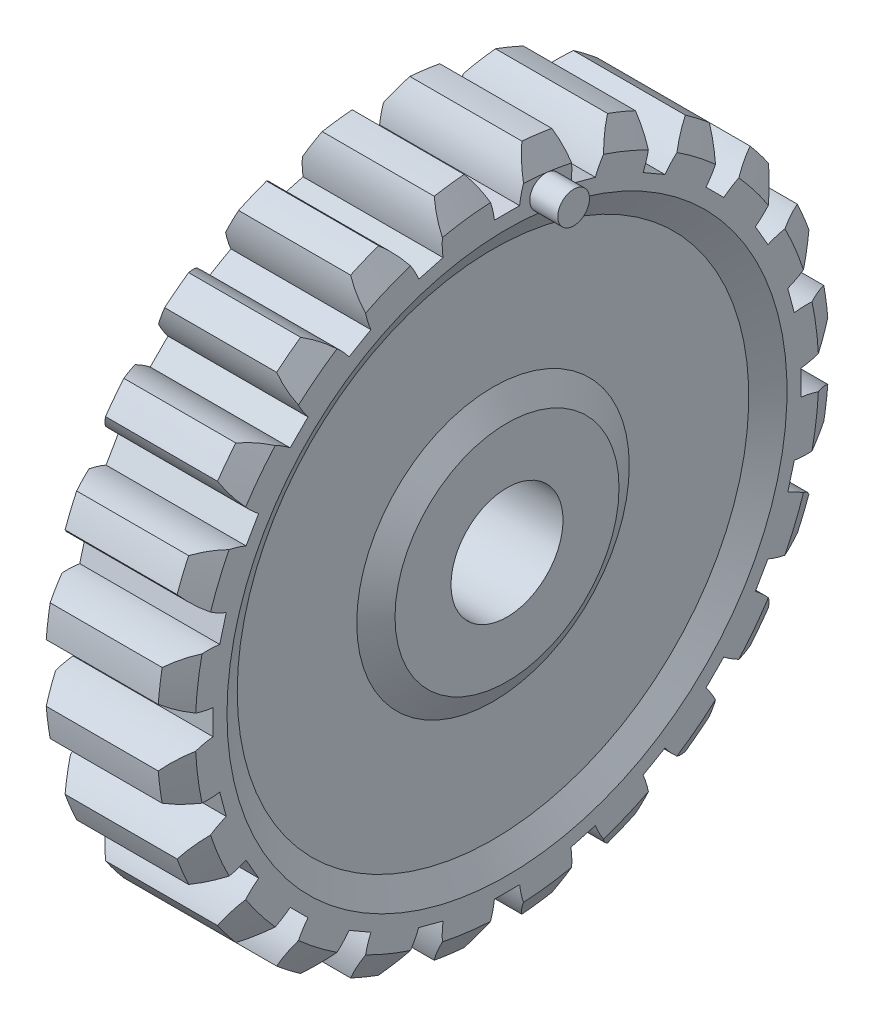
from build123d import *

# Parameters (mm, degrees)
CUT_EXTRUDE1_DEPTH  = 32.75
CIRPATTERN1_COUNT   = 24
SKETCH4_R           = 3.600369343
BOSS_EXTRUDE2_DEPTH = 6.35


with BuildPart() as part:
    # Sketch1 → Revolve1 (revolve)
    with BuildSketch(Plane.XY):
        Polygon((15.875, 12.7), (-15.875, 12.7), (-15.875, 25.4), (-12.7, 30.899261314), (-12.7, 58.000738686), (-15.875, 63.5), (-15.875, 70.700738686), (-12.7, 76.2), (12.7, 76.2), (15.875, 70.700738686), (15.875, 63.5), (12.7, 58.000738686), (12.7, 30.899261314), (15.875, 25.4), align=None)
    revolve(axis=Axis((0, 0, 0), (1, 0, 0)))

    # Sketch3 → Cut-Extrude1 (cut, through all)
    with BuildSketch(Plane(origin=(15.875, 0, 0), x_dir=(0, 0, -1), z_dir=(1, 0, 0))):
        with BuildLine():
            Line((-2.8575, 66.675), (2.8575, 66.675))
            ThreePointArc((2.8575, 66.675), (4.084797701, 71.541608863), (6.5405, 75.91878463))
            ThreePointArc((6.5405, 75.91878463), (0, 76.2), (-6.5405, 75.91878463))
            ThreePointArc((-6.5405, 75.91878463), (-4.084797701, 71.541608863), (-2.8575, 66.675))
        make_face()
    cut_extrude1 = extrude(amount=-CUT_EXTRUDE1_DEPTH, mode=Mode.SUBTRACT)

    # CirPattern1: Cut-Extrude1 ×24 about axis
    cirpattern1_axis = Axis((0, 0, 0), (1, 0, 0))
    for i in range(1, CIRPATTERN1_COUNT):
        add(cut_extrude1.rotate(cirpattern1_axis, i * 360 / CIRPATTERN1_COUNT), mode=Mode.SUBTRACT)

    # Sketch4 → Boss-Extrude2 (add)
    with BuildSketch(Plane(origin=(15.875, 0, 0), x_dir=(0, 0, -1), z_dir=(1, 0, 0))):
        with Locations((8.758355707, 66.526316381)):
            Circle(SKETCH4_R)
    extrude(amount=BOSS_EXTRUDE2_DEPTH)


solid = part.part
